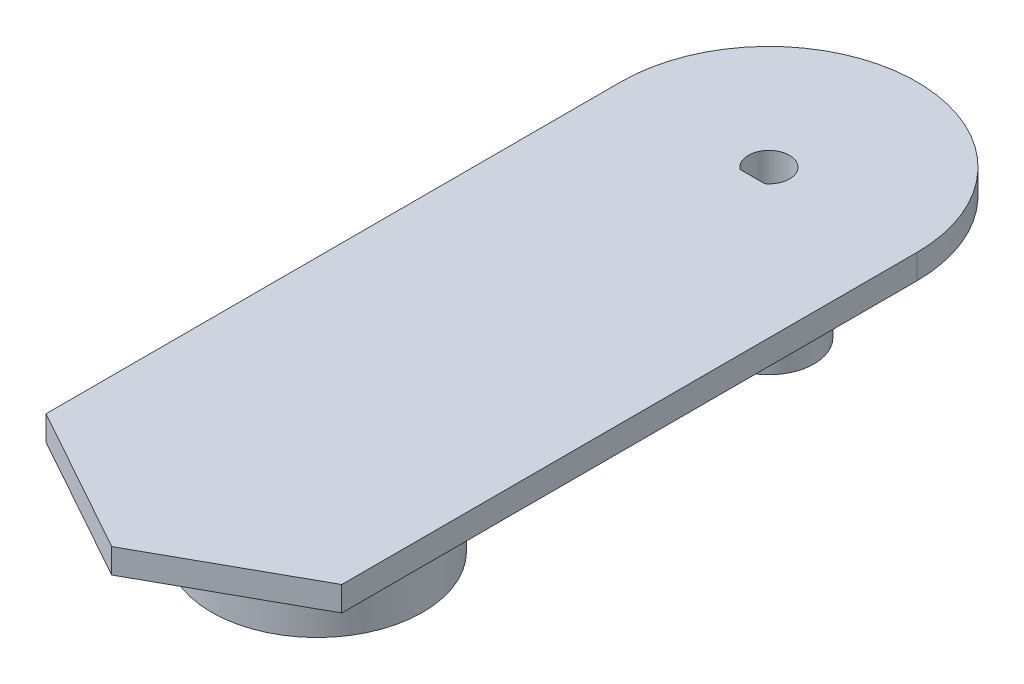
from build123d import *

# Parameters (mm, degrees)
SKETCH1_R           = 5.5
BOSS_EXTRUDE1_DEPTH = 15
SKETCH2_R           = 18
SKETCH2_R_2         = 5.5
BOSS_EXTRUDE3_DEPTH = 3
SKETCH3_R           = 12.86
SKETCH3_R_2         = 9.86
BOSS_EXTRUDE4_DEPTH = 10


with BuildPart() as part:
    # Sketch1 → Boss-Extrude1 (new body)
    with BuildSketch(Plane(origin=(0, 0, 0), x_dir=(1, 0, 0), z_dir=(0, 1, 0))):
        with Locations(Location((2.5, 2.5, 0), (0, 0, 270))):
            Circle(SKETCH1_R)
        with BuildLine():
            Line((4, 0.5), (1, 0.5))
            ThreePointArc((1, 0.5), (2.5, 5), (4, 0.5))
        make_face(mode=Mode.SUBTRACT)
    extrude(amount=BOSS_EXTRUDE1_DEPTH)

    # Sketch2 → Boss-Extrude3 (add)
    with BuildSketch(Plane(origin=(0, 15, 0), x_dir=(1, 0, 0), z_dir=(0, 1, 0))):
        with Locations((2.5, 2.5)):
            Circle(SKETCH2_R)
        with Locations(Location((2.5, 2.5, 0), (0, 0, 270))):
            Circle(SKETCH2_R_2, mode=Mode.SUBTRACT)
        with Locations(Location((2.5, 2.5, 0), (0, 0, 270))):
            Circle(SKETCH2_R_2)
        with BuildLine():
            Line((4, 0.5), (1, 0.5))
            ThreePointArc((1, 0.5), (2.5, 5), (4, 0.5))
        make_face(mode=Mode.SUBTRACT)
        with BuildLine():
            ThreePointArc((20.5, 2.5), (2.5, -15.5), (-15.5, 2.5))
            Line((-15.5, 2.5), (-15.5, -67.5))
            Line((-15.5, -67.5), (2.5, -77.5))
            Line((2.5, -77.5), (20.5, -67.5))
            Line((20.5, -67.5), (20.5, 2.5))
        make_face()
    extrude(amount=BOSS_EXTRUDE3_DEPTH)

    # Sketch3 → Boss-Extrude4 (add)
    with BuildSketch(Plane.XZ.offset(-15)):
        with Locations(Location((2.5, 52.5, 0), (0, 0, 90))):
            Circle(SKETCH3_R)
        with Locations(Location((2.5, 52.5, 0), (0, 0, 270))):
            Circle(SKETCH3_R_2, mode=Mode.SUBTRACT)
    extrude(amount=BOSS_EXTRUDE4_DEPTH)


solid = part.part
